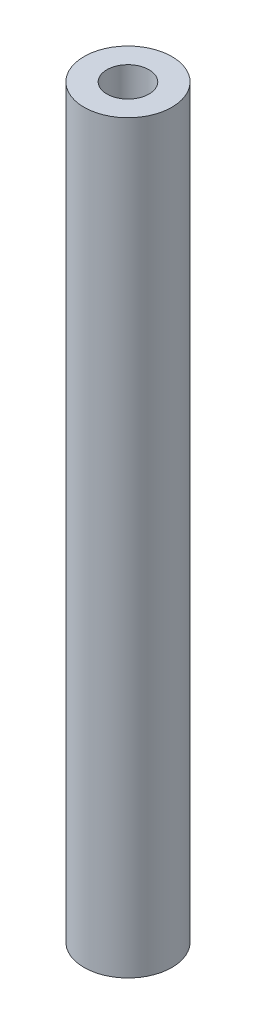
from build123d import *

# Parameters (mm, degrees)
SKETCH1_R           = 3.175
SKETCH1_R_2         = 1.524
BOSS_EXTRUDE1_DEPTH = 53.83403


with BuildPart() as part:
    # Sketch1 → Boss-Extrude1 (new body)
    with BuildSketch(Plane(origin=(0, 0, 0), x_dir=(1, 0, 0), z_dir=(0, 1, 0))):
        Circle(SKETCH1_R)
        Circle(SKETCH1_R_2, mode=Mode.SUBTRACT)
    extrude(amount=BOSS_EXTRUDE1_DEPTH)


solid = part.part
